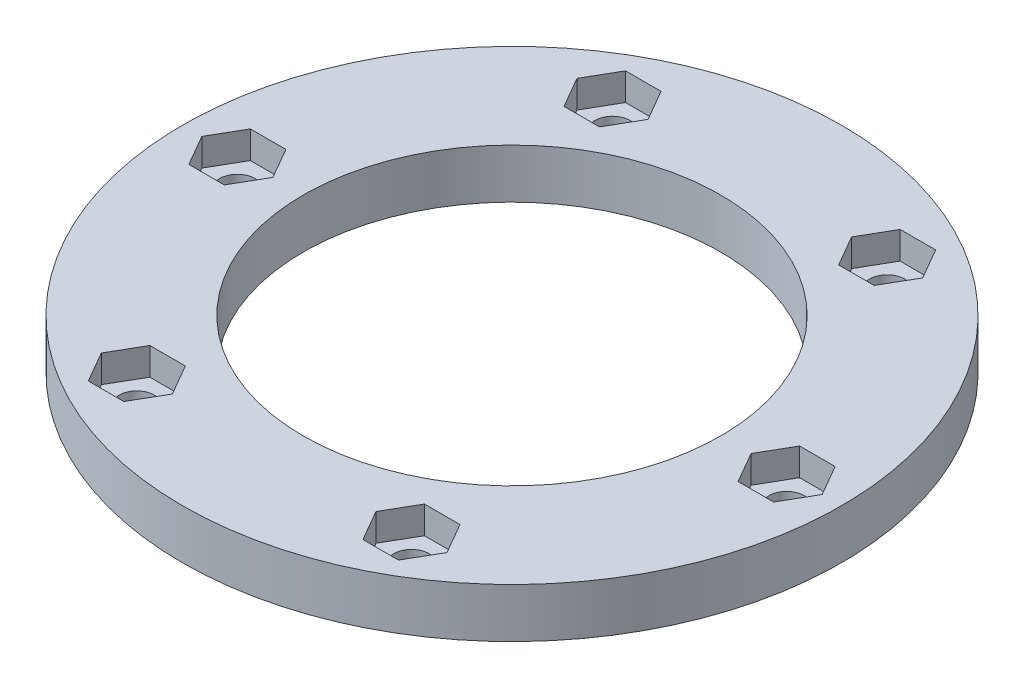
from build123d import *

# Parameters (mm, degrees)
SKETCH1_R           = 30
SKETCH1_R_2         = 19
SKETCH1_R_3         = 1.6
BOSS_EXTRUDE1_DEPTH = 2
SKETCH2_R           = 30
SKETCH2_R_2         = 19
BOSS_EXTRUDE3_DEPTH = 2.5


with BuildPart() as part:
    # Sketch1 → Boss-Extrude1 (new body)
    with BuildSketch(Plane(origin=(0, 0, 0), x_dir=(1, 0, 0), z_dir=(0, 1, 0))):
        Circle(SKETCH1_R)
        Circle(SKETCH1_R_2, mode=Mode.SUBTRACT)
        with Locations((25, 0)):
            Circle(SKETCH1_R_3, mode=Mode.SUBTRACT)
        with Locations((12.5, -21.650635095)):
            Circle(SKETCH1_R_3, mode=Mode.SUBTRACT)
        with Locations((-12.5, -21.650635095)):
            Circle(SKETCH1_R_3, mode=Mode.SUBTRACT)
        with Locations((-25, 0)):
            Circle(SKETCH1_R_3, mode=Mode.SUBTRACT)
        with Locations((-12.5, 21.650635095)):
            Circle(SKETCH1_R_3, mode=Mode.SUBTRACT)
        with Locations((12.5, 21.650635095)):
            Circle(SKETCH1_R_3, mode=Mode.SUBTRACT)
    extrude(amount=BOSS_EXTRUDE1_DEPTH)

    # Sketch2 → Boss-Extrude3 (add)
    with BuildSketch(Plane(origin=(0, 2, 0), x_dir=(1, 0, 0), z_dir=(0, 1, 0))):
        Circle(SKETCH2_R)
        Circle(SKETCH2_R_2, mode=Mode.SUBTRACT)
        Polygon((14.116580754, -24.450635095), (15.733161507, -21.650635095), (14.116580754, -18.850635095), (10.883419246, -18.850635095), (9.266838493, -21.650635095), (10.883419246, -24.450635095), align=None, mode=Mode.SUBTRACT)
        Polygon((28.233161507, 0), (26.616580754, 2.8), (23.383419246, 2.8), (21.766838493, 0), (23.383419246, -2.8), (26.616580754, -2.8), align=None, mode=Mode.SUBTRACT)
        Polygon((-14.116580754, -24.450635095), (-10.883419246, -24.450635095), (-9.266838493, -21.650635095), (-10.883419246, -18.850635095), (-14.116580754, -18.850635095), (-15.733161507, -21.650635095), align=None, mode=Mode.SUBTRACT)
        Polygon((-28.233161507, 0), (-26.616580754, -2.8), (-23.383419246, -2.8), (-21.766838493, 0), (-23.383419246, 2.8), (-26.616580754, 2.8), align=None, mode=Mode.SUBTRACT)
        Polygon((-14.116580754, 24.450635095), (-15.733161507, 21.650635095), (-14.116580754, 18.850635095), (-10.883419246, 18.850635095), (-9.266838493, 21.650635095), (-10.883419246, 24.450635095), align=None, mode=Mode.SUBTRACT)
        Polygon((14.116580754, 24.450635095), (10.883419246, 24.450635095), (9.266838493, 21.650635095), (10.883419246, 18.850635095), (14.116580754, 18.850635095), (15.733161507, 21.650635095), align=None, mode=Mode.SUBTRACT)
    extrude(amount=BOSS_EXTRUDE3_DEPTH)


solid = part.part
